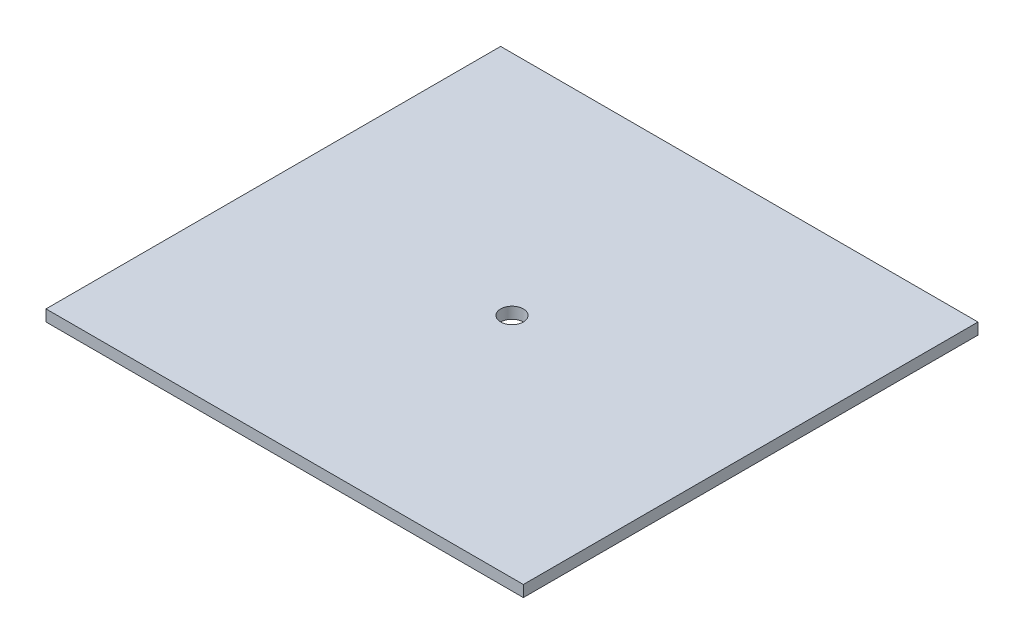
from build123d import *

# Parameters (mm, degrees)
SKETCH1_W           = 133.35
SKETCH1_H           = 127
BOSS_EXTRUDE1_DEPTH = 3.175
SKETCH2_R           = 3.175
CUT_EXTRUDE1_DEPTH  = 4.175


with BuildPart() as part:
    # Sketch1 → Boss-Extrude1 (new body)
    with BuildSketch(Plane(origin=(0, 0, 0), x_dir=(1, 0, 0), z_dir=(0, 1, 0))):
        Rectangle(SKETCH1_W, SKETCH1_H)
    extrude(amount=BOSS_EXTRUDE1_DEPTH)

    # Sketch2 → Cut-Extrude1 (cut, through all)
    with BuildSketch(Plane(origin=(0, 3.175, 0), x_dir=(1, 0, 0), z_dir=(0, 1, 0))):
        Circle(SKETCH2_R)
    extrude(amount=-CUT_EXTRUDE1_DEPTH, mode=Mode.SUBTRACT)


solid = part.part
